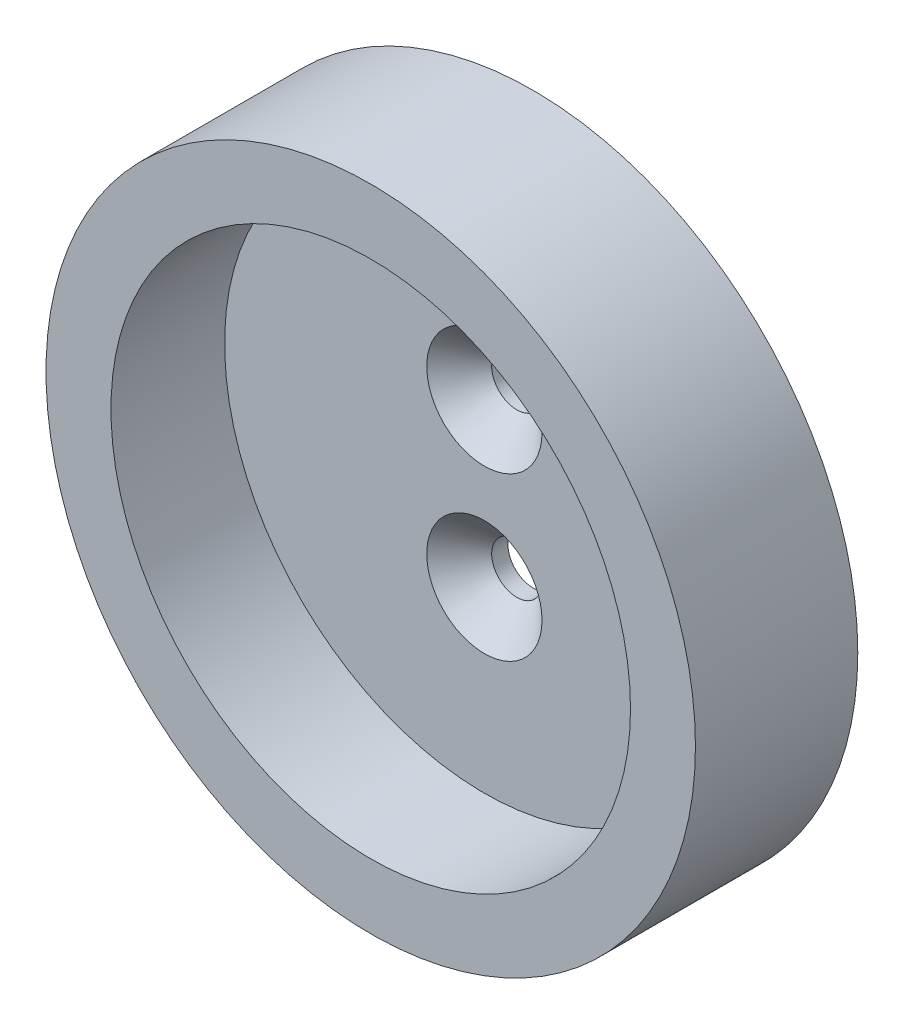
from build123d import *

# Parameters (mm, degrees)
SKETCH1_R           = 20
BOSS_EXTRUDE1_DEPTH = 10
SKETCH2_R           = 16
CUT_EXTRUDE1_DEPTH  = 7
SKETCH3_R           = 1.55
CUT_EXTRUDE2_DEPTH  = 4
CHAMFER1_SIZE       = 2


with BuildPart() as part:
    # Sketch1 → Boss-Extrude1 (new body)
    with BuildSketch(Plane.XY):
        Circle(SKETCH1_R)
    extrude(amount=BOSS_EXTRUDE1_DEPTH)

    # Sketch2 → Cut-Extrude1 (cut)
    with BuildSketch(Plane.XY.offset(10)):
        Circle(SKETCH2_R)
    extrude(amount=-CUT_EXTRUDE1_DEPTH, mode=Mode.SUBTRACT)

    # Sketch3 → Cut-Extrude2 (cut, through all)
    with BuildSketch(Plane.XY.offset(3)):
        with Locations((0, -5)):
            Circle(SKETCH3_R)
        with Locations((0, 5)):
            Circle(SKETCH3_R)
    extrude(amount=-CUT_EXTRUDE2_DEPTH, mode=Mode.SUBTRACT)

    # Chamfer1
    chamfer1_edges = [part.edges().sort_by_distance(p)[0] for p in [
        (-1.55, -5, 3),
        (-1.55, 5, 3),
    ]]
    chamfer(chamfer1_edges, length=CHAMFER1_SIZE)


solid = part.part
